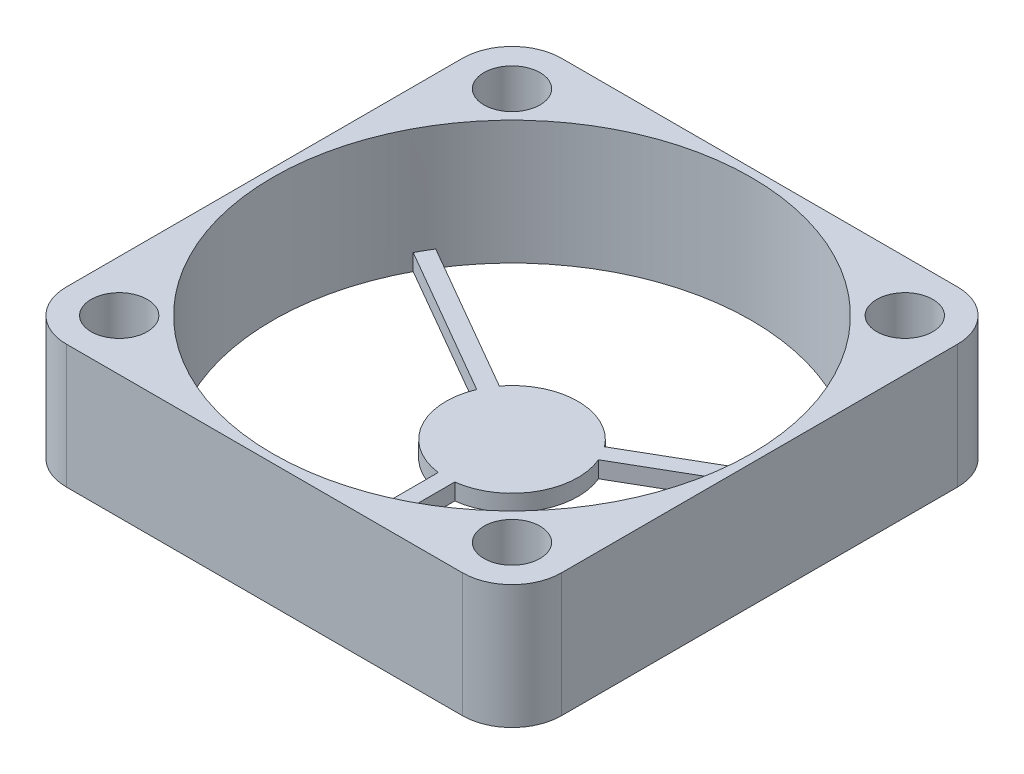
from build123d import *

# Parameters (mm, degrees)
SKETCH1_R           = 1.7
BOSS_EXTRUDE1_DEPTH = 7.5
SKETCH2_R           = 14.5
CUT_EXTRUDE1_DEPTH  = 7.5
SKETCH3_R           = 4
BOSS_EXTRUDE2_DEPTH = 1
BOSS_EXTRUDE3_DEPTH = 1


with BuildPart() as part:
    # Sketch1 → Boss-Extrude1 (new body)
    with BuildSketch(Plane(origin=(0, 0, 0), x_dir=(1, 0, 0), z_dir=(0, 1, 0))):
        with BuildLine():
            Line((-12, -15), (12, -15))
            ThreePointArc((12, -15), (14.121320344, -14.121320344), (15, -12))
            Line((15, -12), (15, 12))
            ThreePointArc((15, 12), (14.121320344, 14.121320344), (12, 15))
            Line((12, 15), (-12, 15))
            ThreePointArc((-12, 15), (-14.121320344, 14.121320344), (-15, 12))
            Line((-15, 12), (-15, -12))
            ThreePointArc((-15, -12), (-14.121320344, -14.121320344), (-12, -15))
        make_face()
        with Locations((-11.9, 11.9)):
            Circle(SKETCH1_R, mode=Mode.SUBTRACT)
        with Locations((11.9, 11.9)):
            Circle(SKETCH1_R, mode=Mode.SUBTRACT)
        with Locations((11.9, -11.9)):
            Circle(SKETCH1_R, mode=Mode.SUBTRACT)
        with Locations((-11.9, -11.9)):
            Circle(SKETCH1_R, mode=Mode.SUBTRACT)
    extrude(amount=BOSS_EXTRUDE1_DEPTH)

    # Sketch2 → Cut-Extrude1 (cut)
    with BuildSketch(Plane(origin=(0, 7.5, 0), x_dir=(1, 0, 0), z_dir=(0, 1, 0))):
        Circle(SKETCH2_R)
    extrude(amount=-CUT_EXTRUDE1_DEPTH, mode=Mode.SUBTRACT)



with BuildPart() as body_2:
    # Sketch3 → Boss-Extrude2 (new body)
    with BuildSketch(Plane.XZ):
        Circle(SKETCH3_R)
    extrude(amount=-BOSS_EXTRUDE2_DEPTH)


with BuildPart() as part_1:
    add(part.part)

    add(body_2.part)  # Boss-Extrude3 merges body 2
    # Sketch4 → Boss-Extrude3 (add)
    with BuildSketch(Plane.XZ):
        with BuildLine():
            Line((-0.5, 14.491376746), (-0.5, 3.968626967))
            ThreePointArc((-0.5, 3.968626967), (0, 4), (0.5, 3.968626967))
            Line((0.5, 3.968626967), (0.5, 14.491376746))
            ThreePointArc((0.5, 14.491376746), (0, 14.5), (-0.5, 14.491376746))
        make_face()
        with BuildLine():
            Line((12.299900398, -7.678701075), (3.186931771, -2.417326185))
            ThreePointArc((3.186931771, -2.417326185), (3.464101615, -2), (3.686931771, -1.551300781))
            Line((3.686931771, -1.551300781), (12.799900398, -6.812675671))
            ThreePointArc((12.799900398, -6.812675671), (12.557368355, -7.25), (12.299900398, -7.678701075))
        make_face()
        with BuildLine():
            Line((-12.799900398, -6.812675671), (-3.686931771, -1.551300781))
            ThreePointArc((-3.686931771, -1.551300781), (-3.464101615, -2), (-3.186931771, -2.417326185))
            Line((-3.186931771, -2.417326185), (-12.299900398, -7.678701075))
            ThreePointArc((-12.299900398, -7.678701075), (-12.557368355, -7.25), (-12.799900398, -6.812675671))
        make_face()
    extrude(amount=-BOSS_EXTRUDE3_DEPTH)


solid = part_1.part
